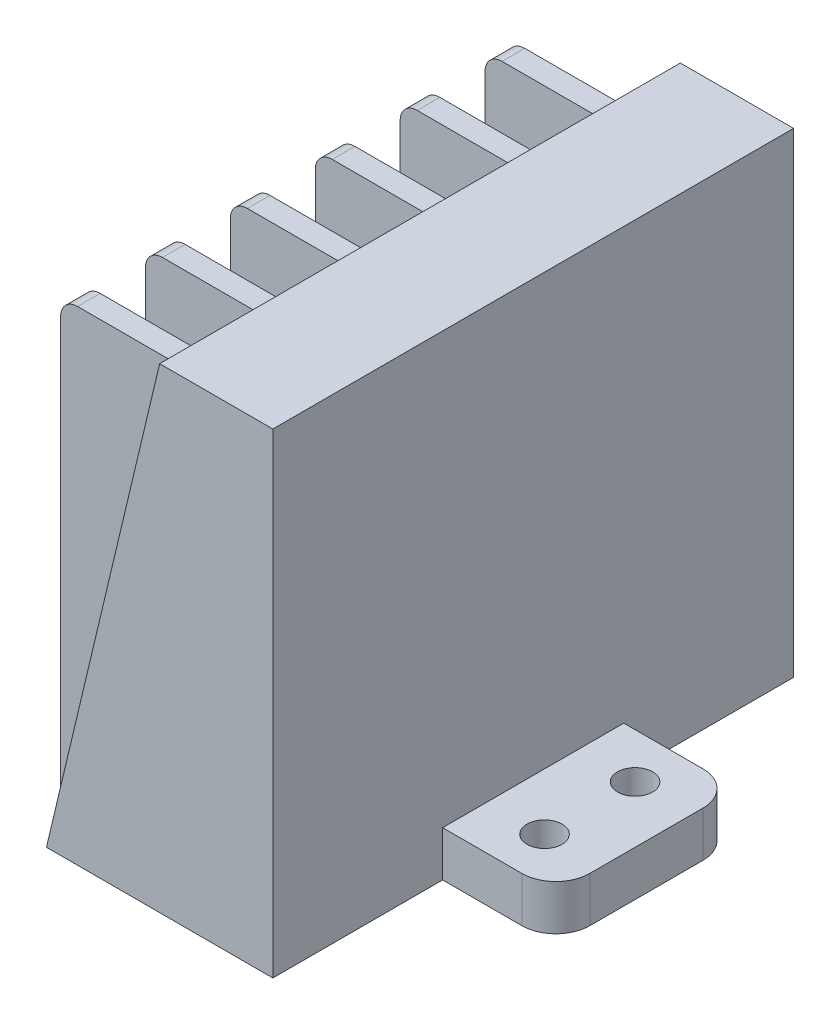
from build123d import *

# Parameters (mm, degrees)
BOSS_EXTRUDE1_DEPTH = 46
BOSS_EXTRUDE2_DEPTH = 2
LPATTERN1_COUNT     = 6
LPATTERN1_PITCH     = 7.5
SKETCH3_W           = 10
SKETCH3_H           = 4
BOSS_EXTRUDE3_DEPTH = 8
CUT_EXTRUDE1_REACH  = 6
SKETCH4_R           = 1.55
FILLET1_R           = 3


with BuildPart() as part:
    # Sketch1 → Boss-Extrude1 (new body)
    with BuildSketch(Plane.XY):
        Polygon((0, 0), (0, 42), (-10, 42), (-20, 0), align=None)
    extrude(amount=BOSS_EXTRUDE1_DEPTH)

    # Sketch2 → Boss-Extrude2 (add)
    with BuildSketch(Plane.XY.offset(42.75)):
        with BuildLine():
            Line((-10.595238095, 39.5), (-20.5, 39.5))
            ThreePointArc((-20.5, 39.5), (-21.560660172, 39.060660172), (-22, 38))
            Line((-22, 38), (-22, 1.5))
            ThreePointArc((-22, 1.5), (-21.560660172, 0.439339828), (-20.5, 0))
            Line((-20.5, 0), (-20, 0))
            Line((-20, 0), (-10.595238095, 39.5))
        make_face()
    boss_extrude2 = extrude(amount=-BOSS_EXTRUDE2_DEPTH)

    # LPattern1: Boss-Extrude2 ×6
    with Locations(*[(0, 0, -i * LPATTERN1_PITCH) for i in range(1, LPATTERN1_COUNT)]):
        add(boss_extrude2)

    # Sketch3 → Boss-Extrude3 (add, symmetric)
    with BuildSketch(Plane.XY.offset(23)):
        with Locations((5, 2)):
            Rectangle(SKETCH3_W, SKETCH3_H)
    extrude(amount=BOSS_EXTRUDE3_DEPTH, both=True)

    # Sketch4 → Cut-Extrude1 (cut, up to next)
    with BuildSketch(Plane(origin=(0, 4, 0), x_dir=(1, 0, 0), z_dir=(0, 1, 0)), mode=Mode.PRIVATE) as cut_extrude1_sk1:
        with Locations((5, -19)):
            Circle(SKETCH4_R)
    cut_extrude1_tool1 = extrude(cut_extrude1_sk1.sketch, amount=-CUT_EXTRUDE1_REACH, mode=Mode.PRIVATE) & part.part
    add(cut_extrude1_tool1.solids().sort_by_distance((5, 4, 19))[0], mode=Mode.SUBTRACT)
    # Sketch4 → Cut-Extrude1 (cut, up to next)
    with BuildSketch(Plane(origin=(0, 4, 0), x_dir=(1, 0, 0), z_dir=(0, 1, 0)), mode=Mode.PRIVATE) as cut_extrude1_sk2:
        with Locations((5, -27)):
            Circle(SKETCH4_R)
    cut_extrude1_tool2 = extrude(cut_extrude1_sk2.sketch, amount=-CUT_EXTRUDE1_REACH, mode=Mode.PRIVATE) & part.part
    add(cut_extrude1_tool2.solids().sort_by_distance((5, 4, 27))[0], mode=Mode.SUBTRACT)

    # Fillet1
    fillet1_edges = [part.edges().sort_by_distance(p)[0] for p in [
        (10, 2, 15),
        (10, 2, 31),
    ]]
    fillet(fillet1_edges, radius=FILLET1_R)


solid = part.part
